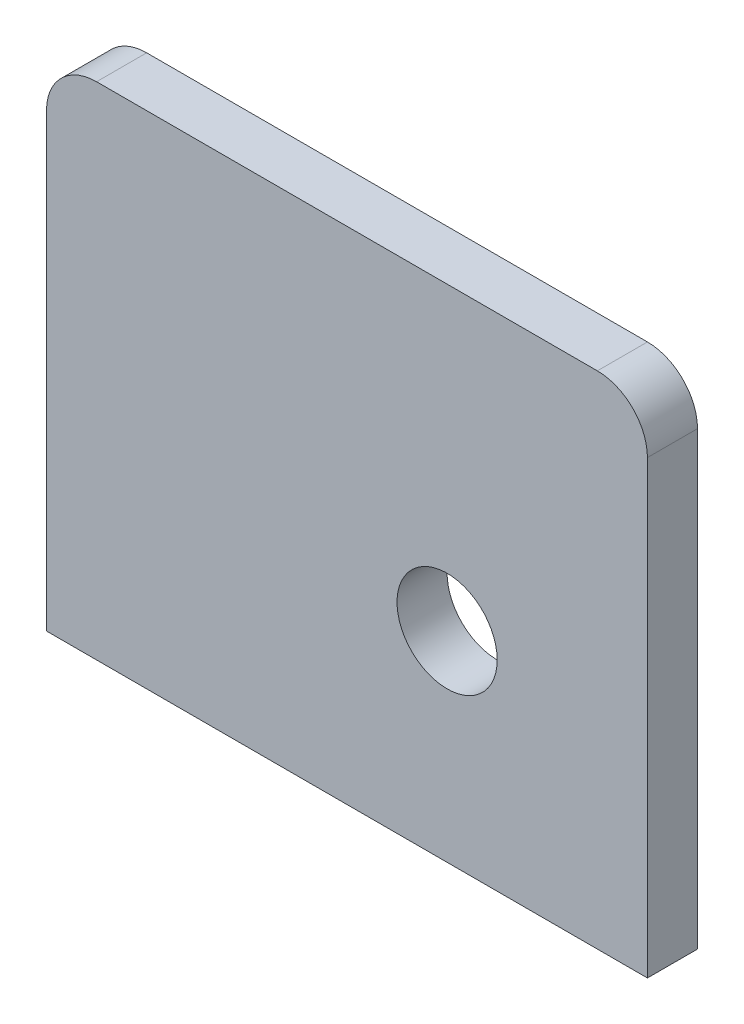
from build123d import *

# Parameters (mm, degrees)
SKETCH1_W           = 76.2
SKETCH1_H           = 63.5
BOSS_EXTRUDE1_DEPTH = 6.35
FILLET1_R           = 6.35
FILLET2_R           = 6.35
SKETCH2_R           = 6.35
CUT_EXTRUDE1_DEPTH  = 7.35


with BuildPart() as part:
    # Sketch1 → Boss-Extrude1 (new body)
    with BuildSketch(Plane.XY):
        with Locations((38.1, 31.75)):
            Rectangle(SKETCH1_W, SKETCH1_H)
    extrude(amount=BOSS_EXTRUDE1_DEPTH)

    # Fillet1
    fillet1_edges = [part.edges().sort_by_distance(p)[0] for p in [
        (0, 63.5, 3.175),
    ]]
    fillet(fillet1_edges, radius=FILLET1_R)

    # Fillet2
    fillet2_edges = [part.edges().sort_by_distance(p)[0] for p in [
        (76.2, 63.5, 3.175),
    ]]
    fillet(fillet2_edges, radius=FILLET2_R)

    # Sketch2 → Cut-Extrude1 (cut, through all)
    with BuildSketch(Plane.XY.offset(6.35)):
        with Locations((50.8, 25.4)):
            Circle(SKETCH2_R)
    extrude(amount=-CUT_EXTRUDE1_DEPTH, mode=Mode.SUBTRACT)


solid = part.part
